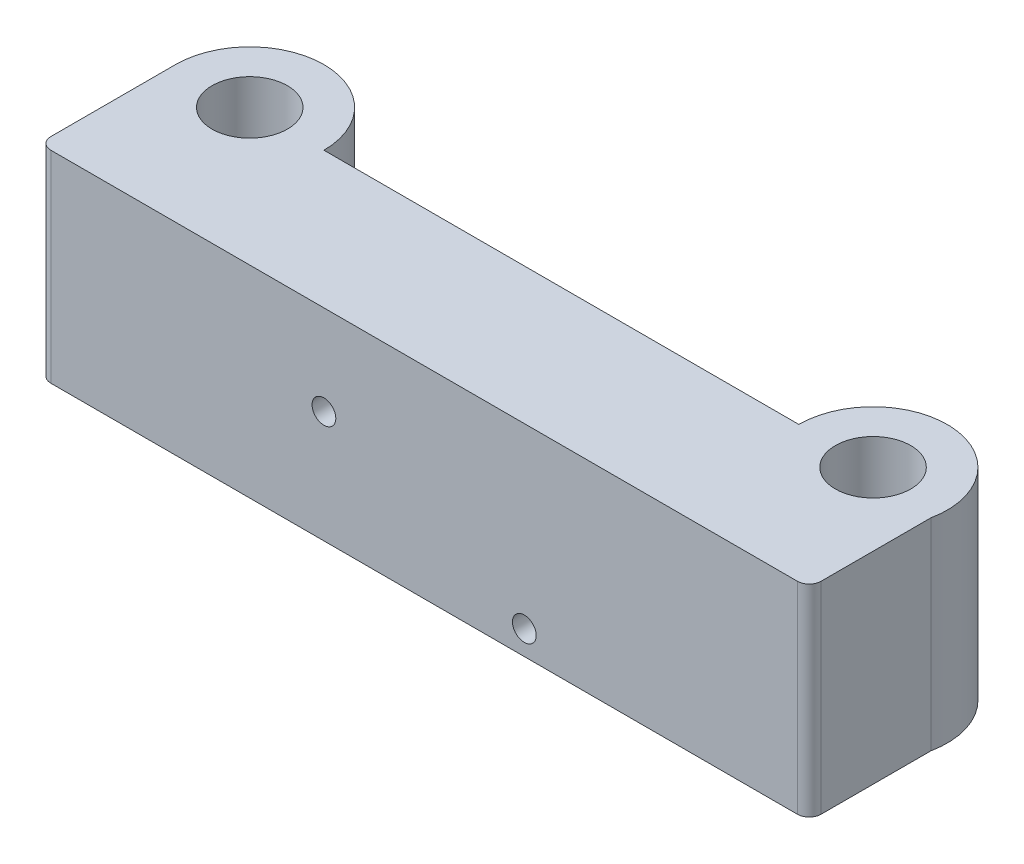
from build123d import *

# Parameters (mm, degrees)
BOSS_EXTRUDE1_DEPTH = 17
SKETCH2_R           = 3.175
CUT_EXTRUDE1_DEPTH  = 18
SKETCH4_R           = 1
CUT_EXTRUDE3_DEPTH  = 18.75
FILLET1_R           = 1


with BuildPart() as part:
    # Sketch1 → Boss-Extrude1 (new body)
    with BuildSketch(Plane(origin=(0, 0, 0), x_dir=(1, 0, 0), z_dir=(0, 1, 0))):
        with BuildLine():
            Line((-24.985807588, 0), (15.020468055, 0))
            ThreePointArc((15.020468055, 0), (21.898649068, 6.218350956), (27.394192412, -1.25))
            Line((27.394192412, -1.25), (27.394192412, -11.5))
            Line((27.394192412, -11.5), (-37.485807588, -11.5))
            Line((-37.485807588, -11.5), (-37.485807588, 0))
            ThreePointArc((-37.485807588, 0), (-31.235807588, 6.25), (-24.985807588, 0))
        make_face()
    extrude(amount=BOSS_EXTRUDE1_DEPTH)

    # Sketch2 → Cut-Extrude1 (cut, through all)
    with BuildSketch(Plane(origin=(0, 17, 0), x_dir=(1, 0, 0), z_dir=(0, 1, 0))):
        with Locations((-31.235807588, 0)):
            Circle(SKETCH2_R)
        with Locations((21.270468055, 0)):
            Circle(SKETCH2_R)
    extrude(amount=-CUT_EXTRUDE1_DEPTH, mode=Mode.SUBTRACT)

    # Sketch4 → Cut-Extrude3 (cut, through all)
    with BuildSketch(Plane.XY.offset(11.5)):
        with Locations((-13.485807588, 9.437)):
            Circle(SKETCH4_R)
        with Locations((3.394192412, 2.037)):
            Circle(SKETCH4_R)
    extrude(amount=-CUT_EXTRUDE3_DEPTH, mode=Mode.SUBTRACT)

    # Fillet1
    fillet1_edges = [part.edges().sort_by_distance(p)[0] for p in [
        (27.394192412, 8.5, 11.5),
        (-37.485807588, 8.5, 11.5),
    ]]
    fillet(fillet1_edges, radius=FILLET1_R)


solid = part.part
